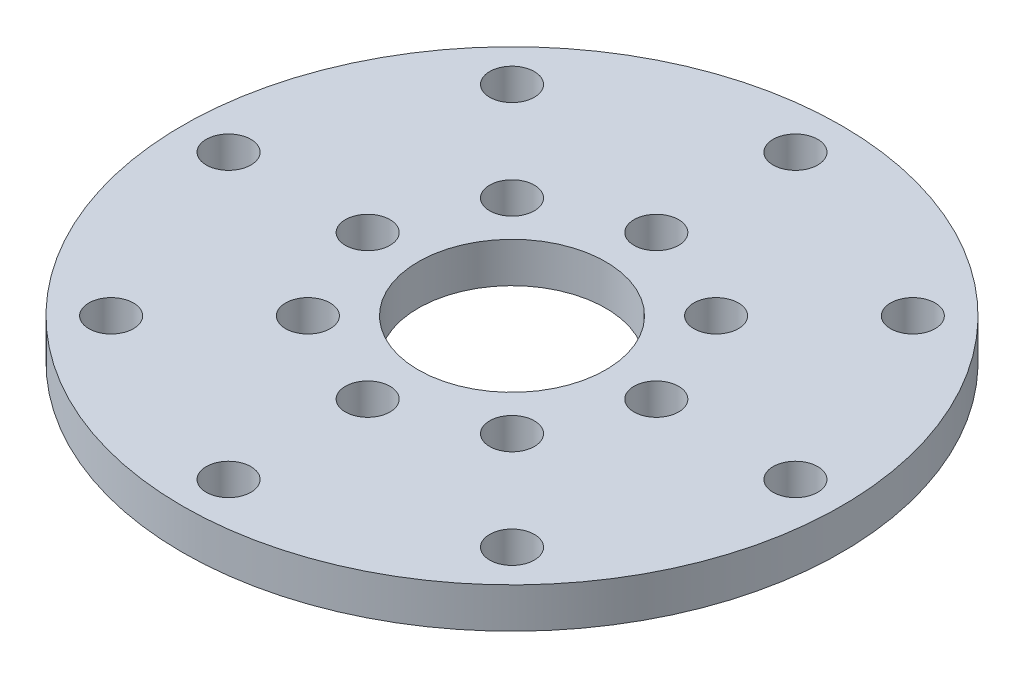
from build123d import *

# Parameters (mm, degrees)
CROQUIS1_R              = 22.15
CROQUIS1_R_2            = 6.3
CROQUIS1_R_3            = 1.5
SALIENTE_EXTRUIR1_DEPTH = 2.7


with BuildPart() as part:
    # Croquis1 → Saliente-Extruir1 (new body)
    with BuildSketch(Plane(origin=(0, 0, 0), x_dir=(1, 0, 0), z_dir=(0, 1, 0))):
        Circle(CROQUIS1_R)
        Circle(CROQUIS1_R_2, mode=Mode.SUBTRACT)
        with Locations((0, 19.05)):
            Circle(CROQUIS1_R_3, mode=Mode.SUBTRACT)
        with Locations((13.470384182, 13.470384182)):
            Circle(CROQUIS1_R_3, mode=Mode.SUBTRACT)
        with Locations((19.05, 0)):
            Circle(CROQUIS1_R_3, mode=Mode.SUBTRACT)
        with Locations((13.470384182, -13.470384182)):
            Circle(CROQUIS1_R_3, mode=Mode.SUBTRACT)
        with Locations((0, -19.05)):
            Circle(CROQUIS1_R_3, mode=Mode.SUBTRACT)
        with Locations((-13.470384182, -13.470384182)):
            Circle(CROQUIS1_R_3, mode=Mode.SUBTRACT)
        with Locations((-19.05, 0)):
            Circle(CROQUIS1_R_3, mode=Mode.SUBTRACT)
        with Locations((-13.470384182, 13.470384182)):
            Circle(CROQUIS1_R_3, mode=Mode.SUBTRACT)
        with Locations((0, 9.7)):
            Circle(CROQUIS1_R_3, mode=Mode.SUBTRACT)
        with Locations((6.858935778, 6.858935778)):
            Circle(CROQUIS1_R_3, mode=Mode.SUBTRACT)
        with Locations((9.7, 0)):
            Circle(CROQUIS1_R_3, mode=Mode.SUBTRACT)
        with Locations((6.858935778, -6.858935778)):
            Circle(CROQUIS1_R_3, mode=Mode.SUBTRACT)
        with Locations((0, -9.7)):
            Circle(CROQUIS1_R_3, mode=Mode.SUBTRACT)
        with Locations((-6.858935778, -6.858935778)):
            Circle(CROQUIS1_R_3, mode=Mode.SUBTRACT)
        with Locations((-9.7, 0)):
            Circle(CROQUIS1_R_3, mode=Mode.SUBTRACT)
        with Locations((-6.858935778, 6.858935778)):
            Circle(CROQUIS1_R_3, mode=Mode.SUBTRACT)
    extrude(amount=SALIENTE_EXTRUIR1_DEPTH)


solid = part.part
